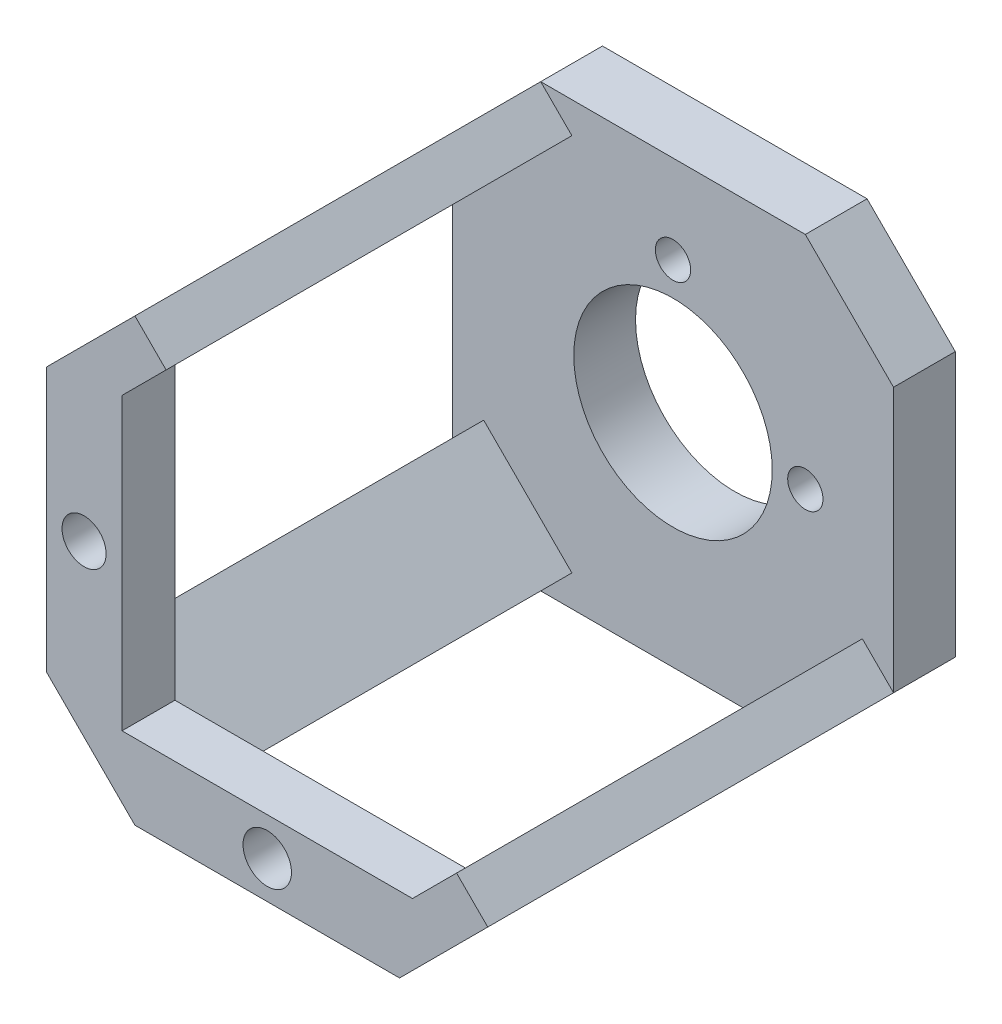
from build123d import *

# Parameters (mm, degrees)
ESQUISSE1_W             = 50
ESQUISSE1_H             = 50
BOSS_EXTRU_1_DEPTH      = 7
CHANFREIN1_SIZE         = 10
BOSS_EXTRU_2_DEPTH      = 40
BOSS_EXTRU_3_DEPTH      = 6
ESQUISSE5_R             = 11.25
ENL_V_MAT_EXTRU_1_DEPTH = 7
ESQUISSE6_R             = 2.5
ESQUISSE6_R_2           = 2.745007664
ENL_V_MAT_EXTRU_2_DEPTH = 6
ESQUISSE7_R             = 2
ENL_V_MAT_EXTRU_3_DEPTH = 7


with BuildPart() as part:
    # Esquisse1 → Boss.-Extru.1 (new body)
    with BuildSketch(Plane.XY):
        with Locations((-1.883571087, -2.012711864)):
            Rectangle(ESQUISSE1_W, ESQUISSE1_H)
    extrude(amount=BOSS_EXTRU_1_DEPTH)

    # Chanfrein1
    chanfrein1_edges = [part.edges().sort_by_distance(p)[0] for p in [
        (-26.883571087, 22.987288136, 3.5),
        (23.116428913, 22.987288136, 3.5),
        (23.116428913, -27.012711864, 3.5),
        (-26.883571087, -27.012711864, 3.5),
    ]]
    chamfer(chanfrein1_edges, length=CHANFREIN1_SIZE)

    # Esquisse2 → Boss.-Extru.2 (add)
    with BuildSketch(Plane.XY.offset(7)):
        Polygon((-23.348037181, 9.45175423), (-26.883571087, 12.987288136), (-16.883571087, 22.987288136), (-13.348037181, 19.45175423), align=None)
        Polygon((19.580895007, -13.477177958), (9.580895007, -23.477177958), (13.116428913, -27.012711864), (23.116428913, -17.012711864), align=None)
        Polygon((-13.348037181, -23.477177958), (-23.348037181, -13.477177958), (-26.883571087, -17.012711864), (-16.883571087, -27.012711864), align=None)
    extrude(amount=BOSS_EXTRU_2_DEPTH)

    # Esquisse4 → Boss.-Extru.3 (add)
    with BuildSketch(Plane.XY.offset(47)):
        Polygon((-18.348037181, 14.45175423), (-13.348037181, 19.45175423), (-16.883571087, 22.987288136), (-26.883571087, 12.987288136), (-26.883571087, -17.012711864), (-16.883571087, -27.012711864), (13.116428913, -27.012711864), (23.116428913, -17.012711864), (19.580895007, -13.477177958), (14.580895007, -18.477177958), (-18.348037181, -18.477177958), align=None)
    extrude(amount=BOSS_EXTRU_3_DEPTH)

    # Esquisse5 → Enlèv. mat.-Extru.1 (cut)
    with BuildSketch(Plane(origin=(0, 0, 0), x_dir=(-1, 0, 0), z_dir=(0, 0, -1))):
        with Locations((1.883571087, -2.012711864)):
            Circle(ESQUISSE5_R)
    extrude(amount=-ENL_V_MAT_EXTRU_1_DEPTH, mode=Mode.SUBTRACT)

    # Esquisse6 → Enlèv. mat.-Extru.2 (cut)
    with BuildSketch(Plane.XY.offset(53)):
        with Locations((-22.648037181, -2.012711864)):
            Circle(ESQUISSE6_R)
        with Locations((-1.883571087, -22.777177958)):
            Circle(ESQUISSE6_R_2)
    extrude(amount=-ENL_V_MAT_EXTRU_2_DEPTH, mode=Mode.SUBTRACT)

    # Esquisse7 → Enlèv. mat.-Extru.3 (cut)
    with BuildSketch(Plane(origin=(0, 0, 0), x_dir=(-1, 0, 0), z_dir=(0, 0, -1))):
        with Locations((1.883571087, 12.987288136)):
            Circle(ESQUISSE7_R)
        with Locations((-13.116428913, -2.012711864)):
            Circle(ESQUISSE7_R)
    extrude(amount=-ENL_V_MAT_EXTRU_3_DEPTH, mode=Mode.SUBTRACT)


solid = part.part
